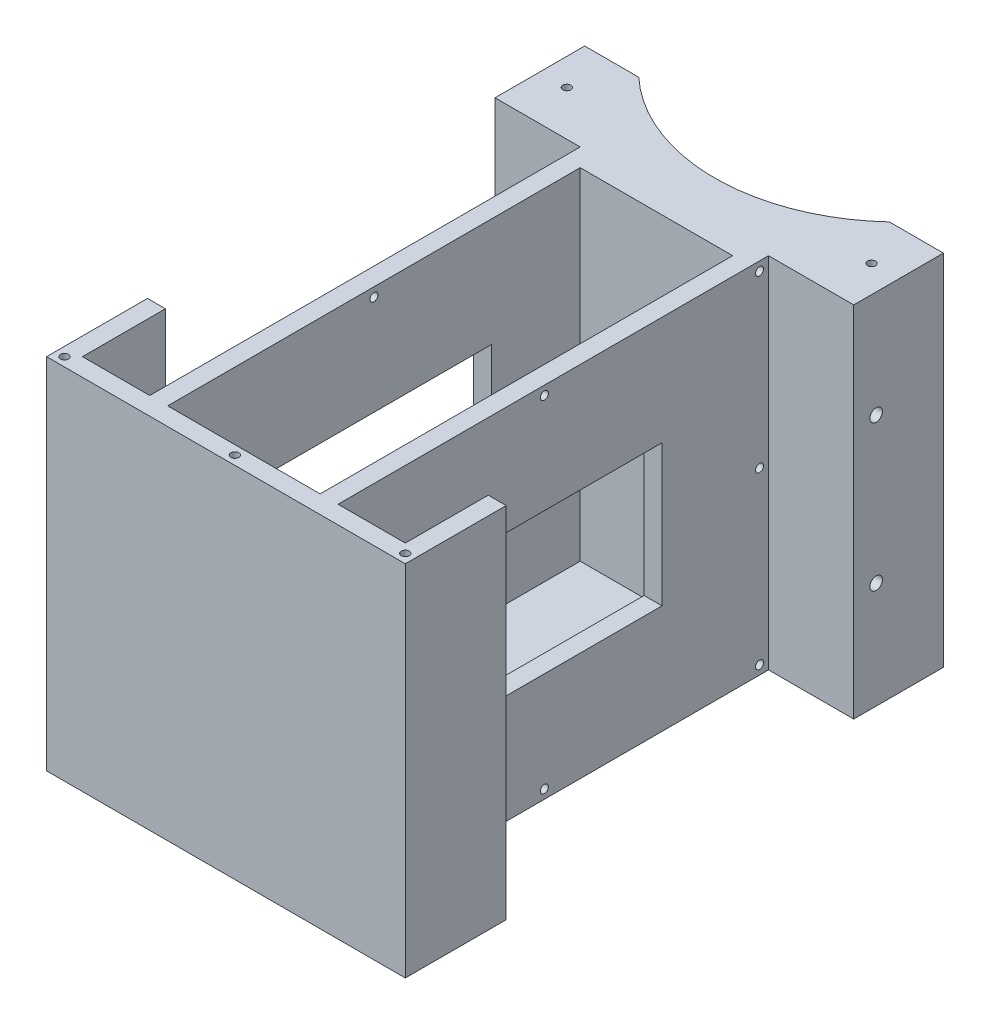
from build123d import *

# Parameters (mm, degrees)
SKETCH_1_W                  = 80
SKETCH_1_H                  = 120
EXTRUDE_1_DEPTH             = 80
SKETCH_2_W                  = 19
SKETCH_2_H                  = 100
CUT_EXTRUDE_1_DEPTH         = 81
SKETCH_3_W                  = 19
SKETCH_3_H                  = 100
CUT_EXTRUDE_2_DEPTH         = 81
CUT_EXTRUDE_3_DEPTH         = 81
SKETCH_5_W                  = 34
SKETCH_5_H                  = 92
CUT_EXTRUDE_4_DEPTH         = 76
CUT_EXTRUDE_5_REACH         = 63
SKETCH_6_W                  = 49.5
SKETCH_6_H                  = 31.5
SKETCH_7_W                  = 49.5
SKETCH_7_H                  = 31.5
CUT_EXTRUDE_6_DEPTH         = 62
HOLE_WIZARD_1_8_1_8_5_D     = 1.8
HOLE_WIZARD_1_8_1_8_5_DEPTH = 4
HOLE_WIZARD_16_0_16_1_D     = 16
HOLE_WIZARD_1_8_1_8_4_D     = 1.8
HOLE_WIZARD_1_8_1_8_4_DEPTH = 4
HOLE_WIZARD_1_8_1_8_4_TIP   = 0.540774557
HOLE_WIZARD_1_8_1_8_3_D     = 1.8
HOLE_WIZARD_1_8_1_8_1_D     = 1.8
HOLE_WIZARD_1_8_1_8_1_DEPTH = 5.2
HOLE_WIZARD_1_8_1_8_1_TIP   = 0.540774557
HOLE_WIZARD_1_8_1_8_2_D     = 1.8
HOLE_WIZARD_1_8_1_8_2_DEPTH = 4
HOLE_WIZARD_1_8_1_8_2_TIP   = 0.540774557
EXTRUDE_2_DEPTH             = 80
SKETCH_21_R                 = 1.4
CUT_EXTRUDE_7_DEPTH         = 8
SKETCH_22_R                 = 1.4
CUT_EXTRUDE_8_DEPTH         = 8
SKETCH_23_R                 = 0.9
CUT_EXTRUDE_9_DEPTH         = 2


with BuildPart() as part:
    # 스케치1 → 보스-돌출1 (new body)
    with BuildSketch(Plane(origin=(0, 80, 0), x_dir=(1, 0, 0), z_dir=(0, 1, 0))):
        Rectangle(SKETCH_1_W, SKETCH_1_H)
    extrude(amount=-EXTRUDE_1_DEPTH)

    # 스케치2 → 컷-돌출1 (cut, through all)
    with BuildSketch(Plane.XZ):
        with Locations((-30.5, 10)):
            Rectangle(SKETCH_2_W, SKETCH_2_H)
    extrude(amount=-CUT_EXTRUDE_1_DEPTH, mode=Mode.SUBTRACT)

    # 스케치3 → 컷-돌출2 (cut, through all)
    with BuildSketch(Plane.XZ):
        with Locations((30.5, 10)):
            Rectangle(SKETCH_3_W, SKETCH_3_H)
    extrude(amount=-CUT_EXTRUDE_2_DEPTH, mode=Mode.SUBTRACT)

    # 스케치4 → 컷-돌출3 (cut, through all)
    with BuildSketch(Plane.XZ):
        with BuildLine():
            Line((-27.946377225, -60), (27.946377225, -60))
            ThreePointArc((27.946377225, -60), (0, -49), (-27.946377225, -60))
        make_face()
    extrude(amount=-CUT_EXTRUDE_3_DEPTH, mode=Mode.SUBTRACT)

    # 스케치5 → 컷-돌출4 (cut)
    with BuildSketch(Plane(origin=(0, 80, 0), x_dir=(-1, 0, 0), z_dir=(0, 1, 0))):
        with Locations((0, 10)):
            Rectangle(SKETCH_5_W, SKETCH_5_H)
    extrude(amount=-CUT_EXTRUDE_4_DEPTH, mode=Mode.SUBTRACT)

    # 스케치6 → 컷-돌출5 (cut, up to next)
    with BuildSketch(Plane(origin=(21, 0, 0), x_dir=(0, 0, -1), z_dir=(1, 0, 0)), mode=Mode.PRIVATE) as cut_extrude_5_sk1:
        with Locations((-10, 40)):
            Rectangle(SKETCH_6_W, SKETCH_6_H)
    cut_extrude_5_tool1 = extrude(cut_extrude_5_sk1.sketch, amount=-CUT_EXTRUDE_5_REACH, mode=Mode.PRIVATE) & part.part
    add(cut_extrude_5_tool1.solids().sort_by_distance((21, 40, 10))[0], mode=Mode.SUBTRACT)

    # 스케치7 → 컷-돌출6 (cut, through all)
    with BuildSketch(Plane.ZY.offset(21)):
        with Locations((8.5, 40)):
            Rectangle(SKETCH_7_W, SKETCH_7_H)
    extrude(amount=-CUT_EXTRUDE_6_DEPTH, mode=Mode.SUBTRACT)

    # Ø1.8 (1.8) 지름 구멍5
    with Locations(Plane.ZY.offset(21)):
        with Locations((10, 78)):
            Hole(HOLE_WIZARD_1_8_1_8_5_D / 2, depth=HOLE_WIZARD_1_8_1_8_5_DEPTH)

    # Ø16.0 (16) 지름 구멍1 (through all)
    with Locations(Plane(origin=(0, 0, 0), x_dir=(-1, 0, 0), z_dir=(0, -1, 0))):
        with Locations((0, -22)):
            Hole(HOLE_WIZARD_16_0_16_1_D / 2)

    # Ø1.8 (1.8) 지름 구멍4
    with Locations(Plane.ZY.offset(21)):
        with Locations((-38, 78), (-38, 40), (-38, 2), (10, 2)):
            Hole(HOLE_WIZARD_1_8_1_8_4_D / 2, depth=HOLE_WIZARD_1_8_1_8_4_DEPTH)
            with Locations((0, 0, -(HOLE_WIZARD_1_8_1_8_4_DEPTH + HOLE_WIZARD_1_8_1_8_4_TIP / 2))):  # 118° drill point
                Cone(0, HOLE_WIZARD_1_8_1_8_4_D / 2, HOLE_WIZARD_1_8_1_8_4_TIP, mode=Mode.SUBTRACT)

    # Ø1.8 (1.8) 지름 구멍3 (through all)
    with Locations(Plane(origin=(21, 0, 0), x_dir=(0, 0, -1), z_dir=(1, 0, 0))):
        with Locations((-10, 78)):
            Hole(HOLE_WIZARD_1_8_1_8_3_D / 2)

    # Ø1.8 (1.8) 지름 구멍1
    with Locations(Plane(origin=(0, 80, 0), x_dir=(1, 0, 0), z_dir=(0, 1, 0))):
        with Locations((33.973188612, 50), (-33.973188612, 50)):
            Hole(HOLE_WIZARD_1_8_1_8_1_D / 2, depth=HOLE_WIZARD_1_8_1_8_1_DEPTH)
            with Locations((0, 0, -(HOLE_WIZARD_1_8_1_8_1_DEPTH + HOLE_WIZARD_1_8_1_8_1_TIP / 2))):  # 118° drill point
                Cone(0, HOLE_WIZARD_1_8_1_8_1_D / 2, HOLE_WIZARD_1_8_1_8_1_TIP, mode=Mode.SUBTRACT)

    # Ø1.8 (1.8) 지름 구멍2
    with Locations(Plane(origin=(21, 0, 0), x_dir=(0, 0, -1), z_dir=(1, 0, 0))):
        with Locations((38, 78), (38, 40), (38, 2), (-10, 2)):
            Hole(HOLE_WIZARD_1_8_1_8_2_D / 2, depth=HOLE_WIZARD_1_8_1_8_2_DEPTH)
            with Locations((0, 0, -(HOLE_WIZARD_1_8_1_8_2_DEPTH + HOLE_WIZARD_1_8_1_8_2_TIP / 2))):  # 118° drill point
                Cone(0, HOLE_WIZARD_1_8_1_8_2_D / 2, HOLE_WIZARD_1_8_1_8_2_TIP, mode=Mode.SUBTRACT)

    # 스케치20 → 보스-돌출2 (add)
    with BuildSketch(Plane(origin=(0, 80, 0), x_dir=(1, 0, 0), z_dir=(0, 1, 0))):
        Polygon((40, -37.5), (36, -37.5), (36, -56), (-36, -56), (-36, -37.5), (-40, -37.5), (-40, -60), (40, -60), align=None)
    extrude(amount=-EXTRUDE_2_DEPTH)

    # 스케치21 → 컷-돌출7 (cut)
    with BuildSketch(Plane.ZY.offset(40)):
        with Locations((-45, 23.75)):
            Circle(SKETCH_21_R)
        with Locations((-45, 56.25)):
            Circle(SKETCH_21_R)
    extrude(amount=-CUT_EXTRUDE_7_DEPTH, mode=Mode.SUBTRACT)

    # 스케치22 → 컷-돌출8 (cut)
    with BuildSketch(Plane(origin=(40, 0, 0), x_dir=(0, 0, -1), z_dir=(1, 0, 0))):
        with Locations((45, 23.75)):
            Circle(SKETCH_22_R)
        with Locations((45, 56.25)):
            Circle(SKETCH_22_R)
    extrude(amount=-CUT_EXTRUDE_8_DEPTH, mode=Mode.SUBTRACT)

    # 스케치23 → 컷-돌출9 (cut)
    with BuildSketch(Plane(origin=(0, 80, 0), x_dir=(1, 0, 0), z_dir=(0, 1, 0))):
        with Locations((-38, -58)):
            Circle(SKETCH_23_R)
        with Locations((0, -58)):
            Circle(SKETCH_23_R)
        with Locations((38, -58)):
            Circle(SKETCH_23_R)
    extrude(amount=-CUT_EXTRUDE_9_DEPTH, mode=Mode.SUBTRACT)


solid = part.part
